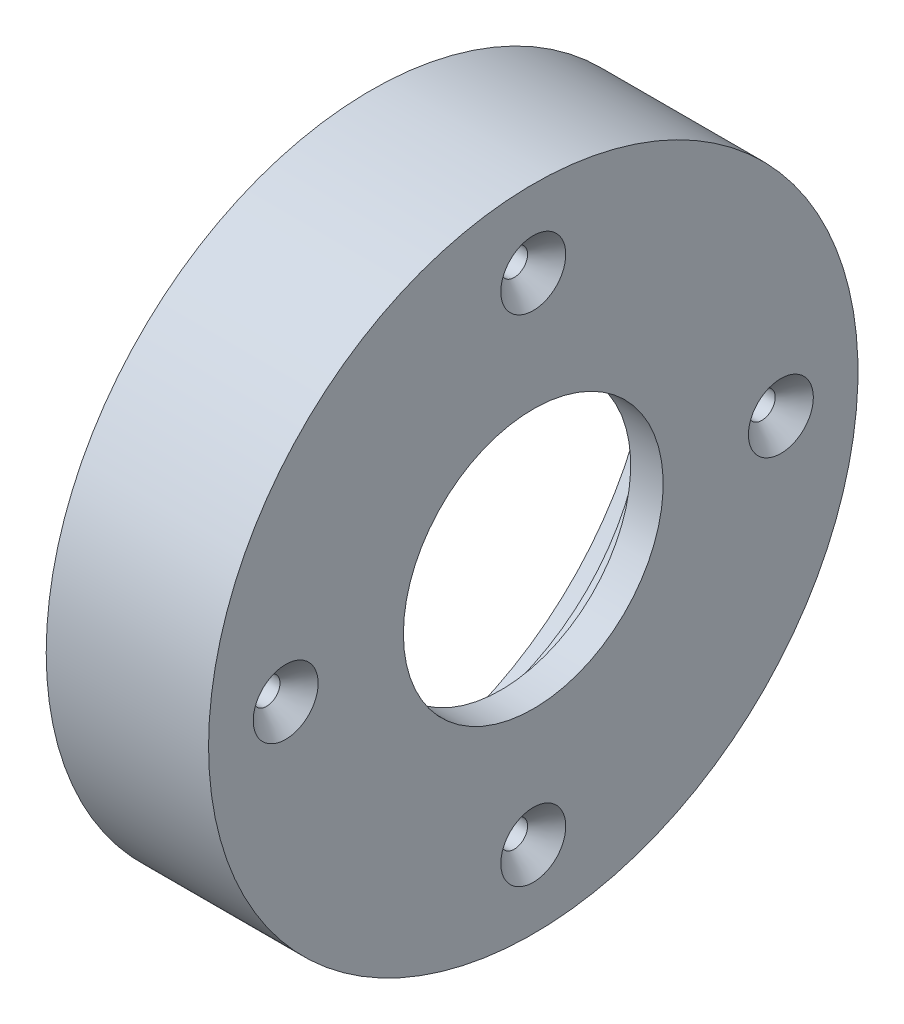
from build123d import *

# Parameters (mm, degrees)
M4X0_7_TAPPED_HOLE1_D           = 3.3
M4X0_7_TAPPED_HOLE1_CSINK_D     = 8
M4X0_7_TAPPED_HOLE1_CSINK_ANGLE = 90


with BuildPart() as part:
    # Sketch2 → Revolve1 (revolve)
    with BuildSketch(Plane.XY):
        Polygon((-14, 40), (6, 40), (6, 16), (2, 16), (2, 21), (0, 21), (0, 23.5), (-4, 23.5), (-4, 35), (-14, 35), align=None)
    revolve(axis=Axis((-28.224413871, 0, 0), (1, 0, 0)))

    # M4x0.7 Tapped Hole1 (through all)
    with Locations(Plane(origin=(6, 0, 0), x_dir=(0, 0, -1), z_dir=(1, 0, 0))):
        with Locations((0, 30.5), (30.5, 0), (0, -30.5), (-30.5, 0)):
            CounterSinkHole(M4X0_7_TAPPED_HOLE1_D / 2, M4X0_7_TAPPED_HOLE1_CSINK_D / 2, counter_sink_angle=M4X0_7_TAPPED_HOLE1_CSINK_ANGLE)


solid = part.part
